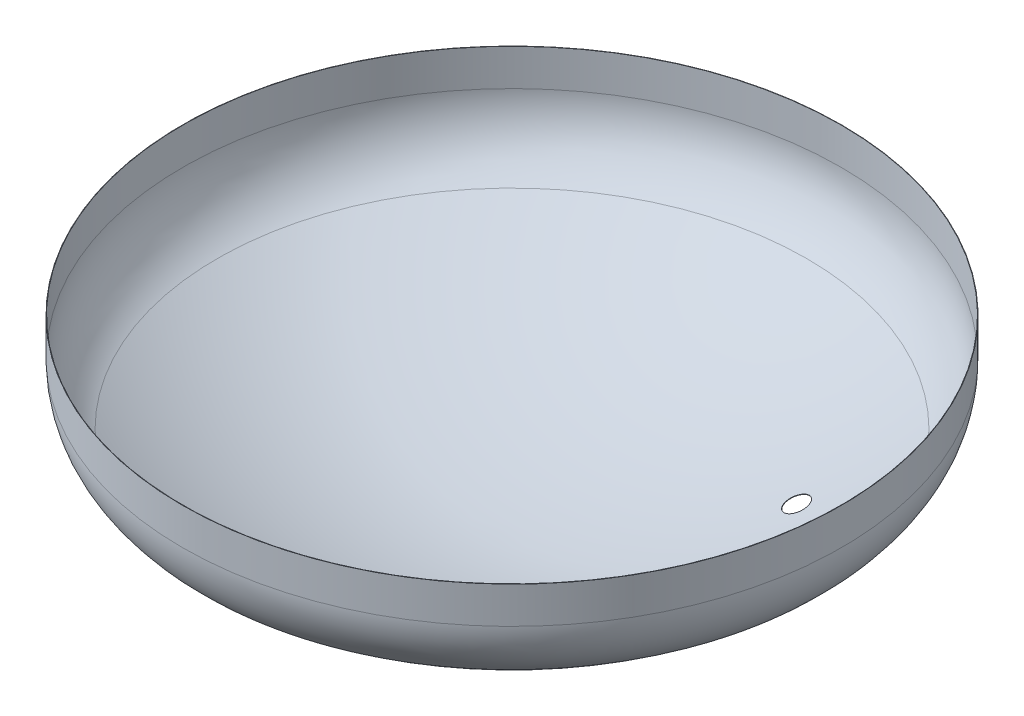
from build123d import *

# Parameters (mm, degrees)
DURCHGANGSLOCH_F_R_M561_D           = 62
DURCHGANGSLOCH_F_R_M561_ON_FACE_2_D = 62
DURCHGANGSLOCH_F_R_M561_ON_FACE_3_D = 62
DURCHGANGSLOCH_F_R_M561_ON_FACE_4_D = 62
DURCHGANGSLOCH_F_R_M561_ON_FACE_5_D = 62
DURCHGANGSLOCH_F_R_M561_ON_FACE_6_D = 62
DURCHGANGSLOCH_F_R_M561_ON_FACE_7_D = 62


with BuildPart() as part:
    # Skizze2 → Rotation-D_nn1 (revolve)
    with BuildSketch(Plane.XY, mode=Mode.PRIVATE) as rotation_d_nn1_sk:
        with BuildLine():
            Line((900, 1200), (900, 1100))
            ThreePointArc((900, 1100), (874.831455224, 1002.871413764), (805.660377358, 930.188679245))
            ThreePointArc((805.660377358, 930.188679245), (418.949720044, 758.675979848), (0, 700))
            Line((0, 700), (0, 701))
            ThreePointArc((0, 701), (418.674998916, 759.637503795), (805.132075472, 931.037735849))
            ThreePointArc((805.132075472, 931.037735849), (873.957297948, 1003.357056695), (899, 1100))
            Line((899, 1100), (899, 1200))
            Line((899, 1200), (900, 1200))
        make_face()
    revolve(rotation_d_nn1_sk.sketch.rotate(Axis((0, 0, 0), (0, 1, 0)), 90), axis=Axis((0, 0, 0), (0, 1, 0)))  # turned: the seam where the file's is

    # Durchgangsloch f_r M561 (through all)
    with Locations(Plane(origin=(691.658204037, 891.573961556, -263.075899291), x_dir=(-0.887685936, -0.460449431, 0), z_dir=(0.453546363, -0.87437773, -0.172508786))):
        with Locations((0, 0)):
            Hole(DURCHGANGSLOCH_F_R_M561_D / 2)

    # Durchgangsloch f_r M561 on face 2 (through all)
    with Locations(Plane(origin=(477.38816392, 891.573961556, 565.420676089), x_dir=(0, -0.390389007, -0.92065), z_dir=(0.313040927, -0.874377797, 0.370767914))):
        with Locations((0, 0)):
            Hole(DURCHGANGSLOCH_F_R_M561_ON_FACE_2_D / 2)

    # Durchgangsloch f_r M561 on face 3 (through all)
    with Locations(Plane(origin=(740, 891.573961556, 0), x_dir=(-0.874377752, -0.485245862, 0), z_dir=(0.485245862, -0.874377752, 0))):
        with Locations((0, 0)):
            Hole(DURCHGANGSLOCH_F_R_M561_ON_FACE_3_D / 2)

    # Durchgangsloch f_r M561 on face 4 (through all)
    with Locations(Plane(origin=(441.411735182, 804.577527635, -336.423364295), x_dir=(-0.954951729, -0.296761176, 0), z_dir=(0.289449942, -0.931424814, -0.220604956))):
        with Locations((0, 0)):
            Hole(DURCHGANGSLOCH_F_R_M561_ON_FACE_4_D / 2)

    # Durchgangsloch f_r M561 on face 5 (through all)
    with Locations(Plane(origin=(555, 804.577527635, 0), x_dir=(-0.931424773, -0.363933911, 0), z_dir=(0.363933911, -0.931424773, 0))):
        with Locations((0, 0)):
            Hole(DURCHGANGSLOCH_F_R_M561_ON_FACE_5_D / 2)

    # Durchgangsloch f_r M561 on face 6 (through all)
    with Locations(Plane(origin=(696.216488153, 891.573961556, 250.764035747), x_dir=(-0.886444368, -0.462835158, 0), z_dir=(0.456535009, -0.874378016, 0.164435003))):
        with Locations((0, 0)):
            Hole(DURCHGANGSLOCH_F_R_M561_ON_FACE_6_D / 2)

    # Durchgangsloch f_r M561 on face 7 (through all)
    with Locations(Plane(origin=(451.200489776, 804.577527635, 323.176605011), x_dir=(-0.953071571, -0.302745076, 0), z_dir=(0.295868903, -0.931424693, 0.21191893))):
        with Locations((1e-09, 0)):
            Hole(DURCHGANGSLOCH_F_R_M561_ON_FACE_7_D / 2)


solid = part.part
